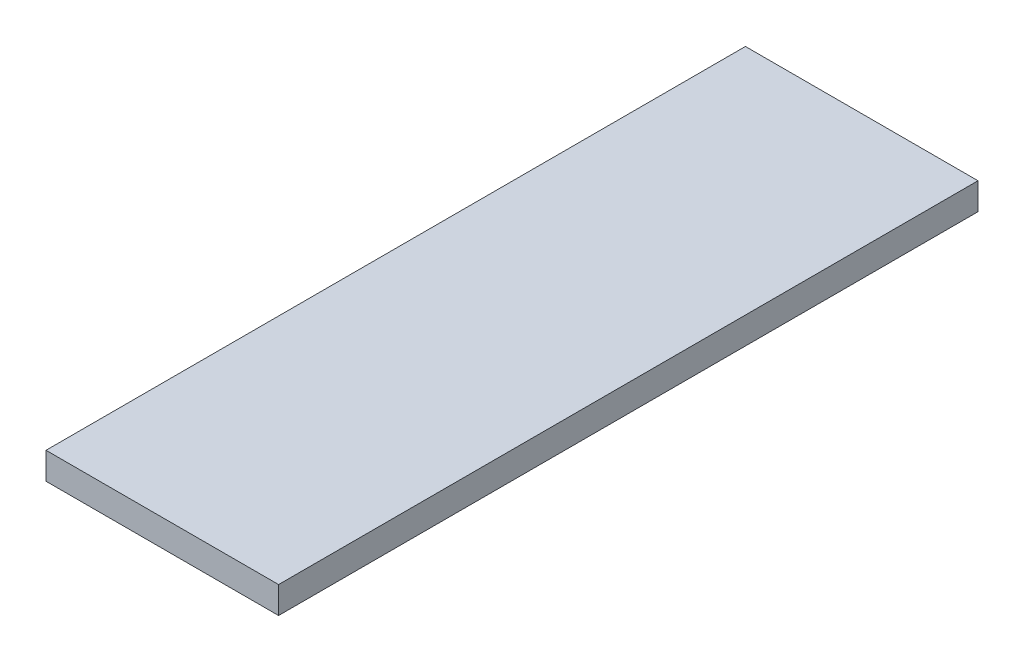
from build123d import *

# Parameters (mm, degrees)
CROQUIS1_W              = 26
CROQUIS1_H              = 78.19
SALIENTE_EXTRUIR1_DEPTH = 3


with BuildPart() as part:
    # Croquis1 → Saliente-Extruir1 (new body)
    with BuildSketch(Plane(origin=(0, 0, 0), x_dir=(1, 0, 0), z_dir=(0, 1, 0))):
        with Locations((13, 39.095)):
            Rectangle(CROQUIS1_W, CROQUIS1_H)
    extrude(amount=SALIENTE_EXTRUIR1_DEPTH)


solid = part.part
